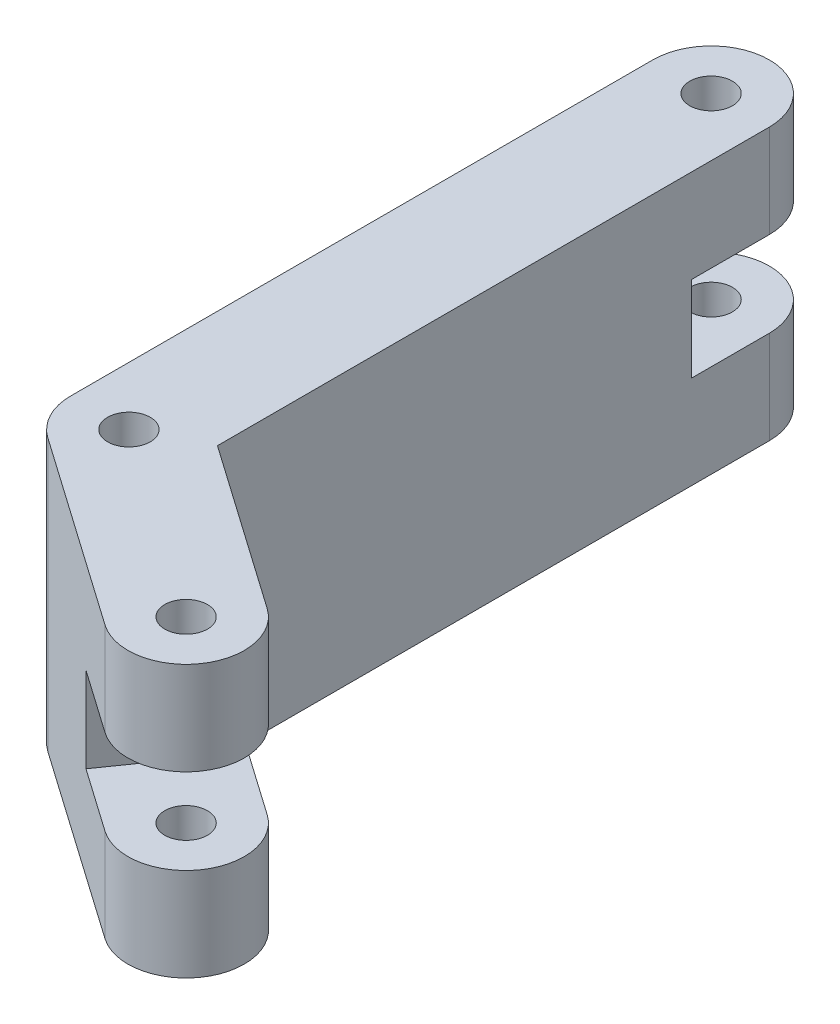
from build123d import *

# Parameters (mm, degrees)
SKETCH2_R           = 2.75
BOSS_EXTRUDE2_DEPTH = 35
CUT_EXTRUDE1_DEPTH  = 35
CUT_EXTRUDE2_DEPTH  = 35


with BuildPart() as part:
    # Sketch2 → Boss-Extrude2 (new body)
    with BuildSketch(Plane(origin=(0, 0, 0), x_dir=(1, 0, 0), z_dir=(0, 1, 0))):
        with BuildLine():
            Line((7.5, 3.904252879), (7.5, 75))
            ThreePointArc((7.5, 75), (0, 82.5), (-7.5, 75))
            Line((-7.5, 75), (-7.5, 0))
            ThreePointArc((-7.5, 0), (-6.652581249, -3.463114599), (-4.301823273, -6.143640332))
            Line((-4.301823273, -6.143640332), (20.272738056, -23.350933423))
            ThreePointArc((20.272738056, -23.350933423), (30.718201661, -21.509116363), (28.876384601, -11.063652758))
            Line((28.876384601, -11.063652758), (7.5, 3.904252879))
        make_face()
        Circle(SKETCH2_R, mode=Mode.SUBTRACT)
        with Locations((0, 75)):
            Circle(SKETCH2_R, mode=Mode.SUBTRACT)
        with Locations((24.574561329, -17.207293091)):
            Circle(SKETCH2_R, mode=Mode.SUBTRACT)
    extrude(amount=BOSS_EXTRUDE2_DEPTH)

    # Sketch3 → Cut-Extrude1 (cut)
    with BuildSketch(Plane(origin=(7.5, 0, 0), x_dir=(0, 0, -1), z_dir=(1, 0, 0))):
        Polygon((75, 12), (65, 12), (65, 23), (87.183204073, 23), (87.183204073, 12), align=None)
    extrude(amount=-CUT_EXTRUDE1_DEPTH, mode=Mode.SUBTRACT)

    # Sketch4 → Cut-Extrude2 (cut)
    with BuildSketch(Plane(origin=(4.301823273, 0, -6.143640332), x_dir=(-0.819152044, 0, -0.573576436), z_dir=(0.573576436, 0, -0.819152044))):
        Polygon((-30, 12), (-30, 17.5), (-30, 23), (-43.630298532, 23), (-43.630298532, 12), align=None)
        Polygon((-30, 23), (-30, 17.5), (-30, 12), (-20, 12), (-20, 23), align=None)
    extrude(amount=-CUT_EXTRUDE2_DEPTH, mode=Mode.SUBTRACT)


solid = part.part
